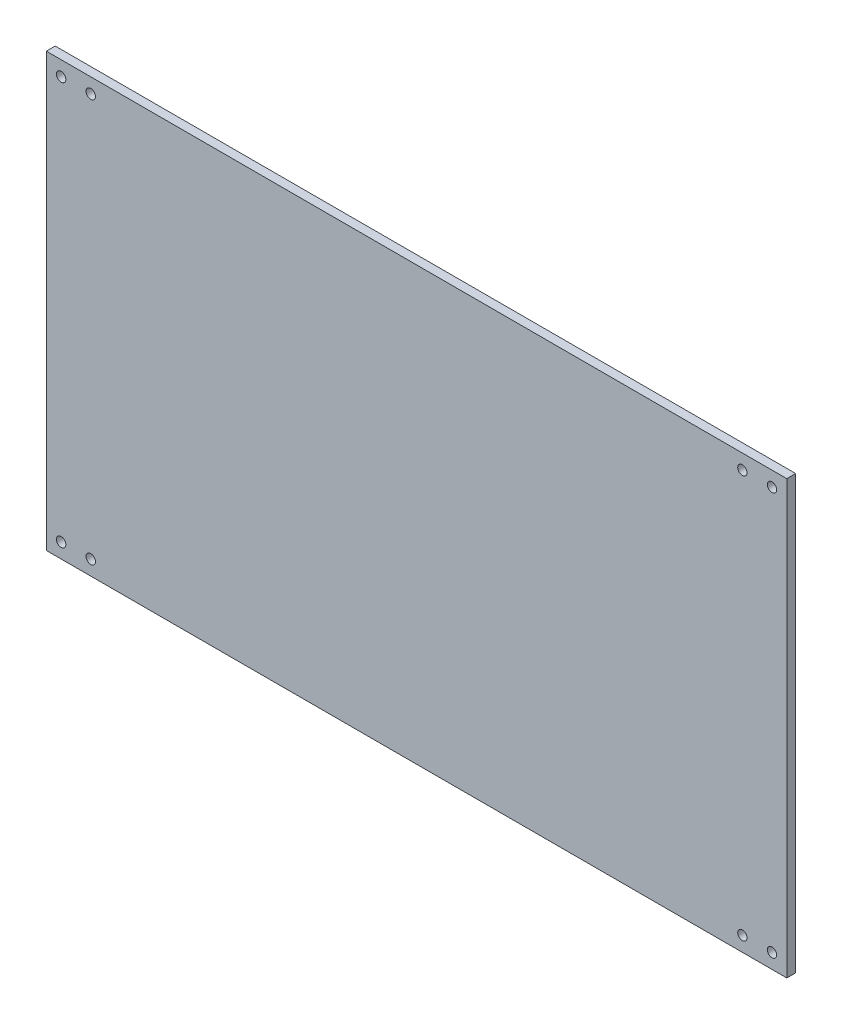
from build123d import *

# Parameters (mm, degrees)
SKETCH_1_W      = 250
SKETCH_1_H      = 146
SKETCH_1_R      = 1.6
SKETCH_1_R_2    = 1.570313995
EXTRUDE_1_DEPTH = 3


with BuildPart() as part:
    # 草图1 → 凸台-拉伸1 (new body)
    with BuildSketch(Plane.XY):
        with Locations((-22.989949749, -3.721105528)):
            Rectangle(SKETCH_1_W, SKETCH_1_H)
        with Locations((-142.989949749, -71.721105528)):
            Circle(SKETCH_1_R, mode=Mode.SUBTRACT)
        with Locations((-132.989949749, -71.721105528)):
            Circle(SKETCH_1_R, mode=Mode.SUBTRACT)
        with Locations((-142.989949749, 64.278894472)):
            Circle(SKETCH_1_R, mode=Mode.SUBTRACT)
        with Locations((-132.989949749, 64.278894472)):
            Circle(SKETCH_1_R, mode=Mode.SUBTRACT)
        with Locations((97.010050251, -71.721105528)):
            Circle(SKETCH_1_R_2, mode=Mode.SUBTRACT)
        with Locations((87.010050251, -71.721105528)):
            Circle(SKETCH_1_R_2, mode=Mode.SUBTRACT)
        with Locations((97.010050251, 64.278894472)):
            Circle(SKETCH_1_R_2, mode=Mode.SUBTRACT)
        with Locations((87.010050251, 64.278894472)):
            Circle(SKETCH_1_R_2, mode=Mode.SUBTRACT)
    extrude(amount=EXTRUDE_1_DEPTH)


solid = part.part
